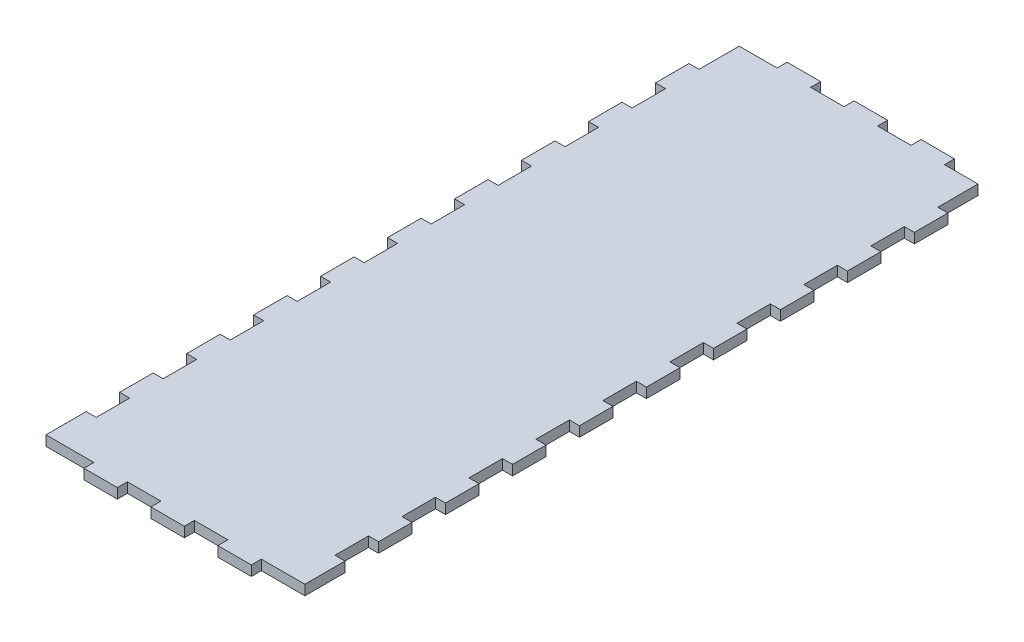
from build123d import *

# Parameters (mm, degrees)
SKETCH1_W           = 35.65
SKETCH1_H           = 204
BOSS_EXTRUDE1_DEPTH = 3
SKETCH2_W           = 12
SKETCH2_H           = 3
SKETCH2_W_2         = 10
BOSS_EXTRUDE2_DEPTH = 3
ESQUISSE1_W         = 10
ESQUISSE1_H         = 3
BOSS_EXTRU_1_DEPTH  = 3
ESQUISSE2_W         = 10
ESQUISSE2_H         = 3
BOSS_EXTRU_2_DEPTH  = 3


with BuildPart() as part:
    # Sketch1 → Boss-Extrude1 (new body)
    with BuildSketch(Plane(origin=(0, 0, 0), x_dir=(1, 0, 0), z_dir=(0, 1, 0))):
        with Locations((17.825, 102)):
            Rectangle(SKETCH1_W, SKETCH1_H)
    boss_extrude1 = extrude(amount=BOSS_EXTRUDE1_DEPTH)

    # Sketch2 → Boss-Extrude2 (add)
    with BuildSketch(Plane(origin=(35.65, 0, 0), x_dir=(0, 0, -1), z_dir=(1, 0, 0))):
        with Locations((6, 1.5)):
            Rectangle(SKETCH2_W, SKETCH2_H)
        with Locations((27, 1.5)):
            Rectangle(SKETCH2_W_2, SKETCH2_H)
        with Locations((47, 1.5)):
            Rectangle(SKETCH2_W_2, SKETCH2_H)
        with Locations((67, 1.5)):
            Rectangle(SKETCH2_W_2, SKETCH2_H)
        with Locations((87, 1.5)):
            Rectangle(SKETCH2_W_2, SKETCH2_H)
        with Locations((107, 1.5)):
            Rectangle(SKETCH2_W_2, SKETCH2_H)
        with Locations((127, 1.5)):
            Rectangle(SKETCH2_W_2, SKETCH2_H)
        with Locations((147, 1.5)):
            Rectangle(SKETCH2_W_2, SKETCH2_H)
        with Locations((167, 1.5)):
            Rectangle(SKETCH2_W_2, SKETCH2_H)
        with Locations((187, 1.5)):
            Rectangle(SKETCH2_W_2, SKETCH2_H)
    boss_extrude2 = extrude(amount=BOSS_EXTRUDE2_DEPTH)

    # Mirror1: Boss-Extrude1, Boss-Extrude2 across plane
    add(boss_extrude1.mirror(Plane(origin=(0, 0, 0), x_dir=(0, 0, 1), z_dir=(1, 0, 0))))
    add(boss_extrude2.mirror(Plane(origin=(0, 0, 0), x_dir=(0, 0, 1), z_dir=(1, 0, 0))))

    # Esquisse1 → Boss.-Extru.1 (add)
    with BuildSketch(Plane(origin=(0, 0, -204), x_dir=(-1, 0, 0), z_dir=(0, 0, -1))):
        with Locations((-20.65, 1.5)):
            Rectangle(ESQUISSE1_W, ESQUISSE1_H)
        with Locations((-0.65, 1.5)):
            Rectangle(ESQUISSE1_W, ESQUISSE1_H)
        with Locations((19.35, 1.5)):
            Rectangle(ESQUISSE1_W, ESQUISSE1_H)
    extrude(amount=BOSS_EXTRU_1_DEPTH)

    # Esquisse2 → Boss.-Extru.2 (add)
    with BuildSketch(Plane.XY):
        with Locations((-19.35, 1.5)):
            Rectangle(ESQUISSE2_W, ESQUISSE2_H)
        with Locations((0.65, 1.5)):
            Rectangle(ESQUISSE2_W, ESQUISSE2_H)
        with Locations((20.65, 1.5)):
            Rectangle(ESQUISSE2_W, ESQUISSE2_H)
    extrude(amount=BOSS_EXTRU_2_DEPTH)


solid = part.part
